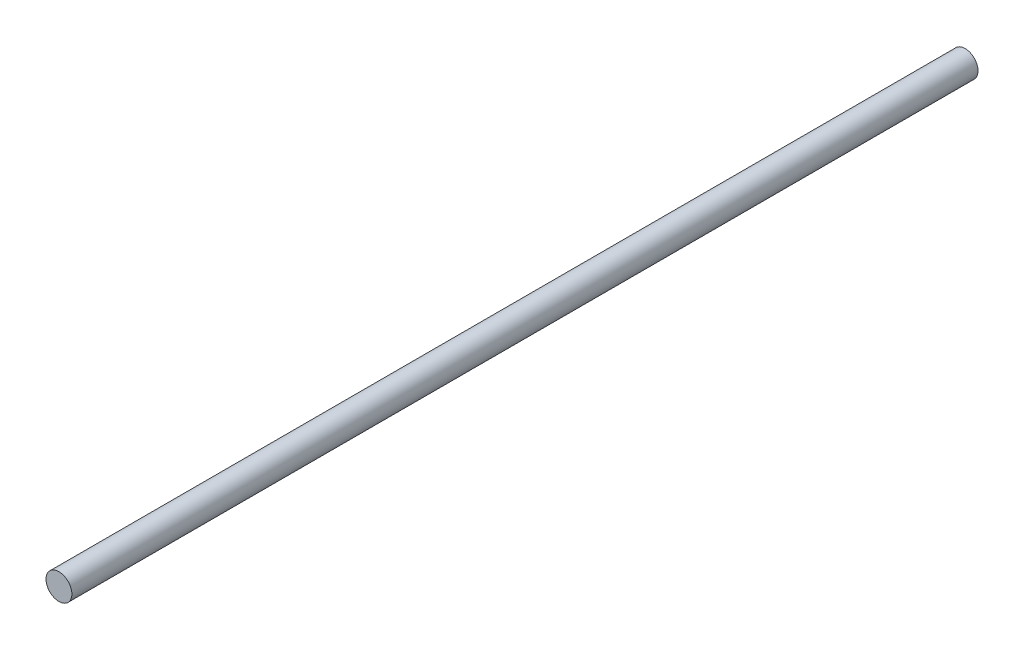
from build123d import *

# Parameters (mm, degrees)
SKETCH1_R           = 4
BOSS_EXTRUDE1_DEPTH = 287.5
SKETCH2_R           = 4
BOSS_EXTRUDE2_DEPTH = 45
SKETCH3_R           = 4
CUT_EXTRUDE1_DEPTH  = 65
SKETCH4_R           = 4
BOSS_EXTRUDE5_DEPTH = 13


with BuildPart() as part:
    # Sketch1 → Boss-Extrude1 (new body)
    with BuildSketch(Plane.XY):
        Circle(SKETCH1_R)
    extrude(amount=BOSS_EXTRUDE1_DEPTH)

    # Sketch2 → Boss-Extrude2 (add)
    with BuildSketch(Plane.XY.offset(287.5)):
        Circle(SKETCH2_R)
    extrude(amount=BOSS_EXTRUDE2_DEPTH)

    # Sketch3 → Cut-Extrude1 (cut)
    with BuildSketch(Plane(origin=(0, 0, 0), x_dir=(-1, 0, 0), z_dir=(0, 0, -1))):
        Circle(SKETCH3_R)
    extrude(amount=-CUT_EXTRUDE1_DEPTH, mode=Mode.SUBTRACT)

    # Sketch4 → Boss-Extrude5 (add)
    with BuildSketch(Plane(origin=(0, 0, 65), x_dir=(-1, 0, 0), z_dir=(0, 0, -1))):
        Circle(SKETCH4_R)
    extrude(amount=BOSS_EXTRUDE5_DEPTH)


solid = part.part
